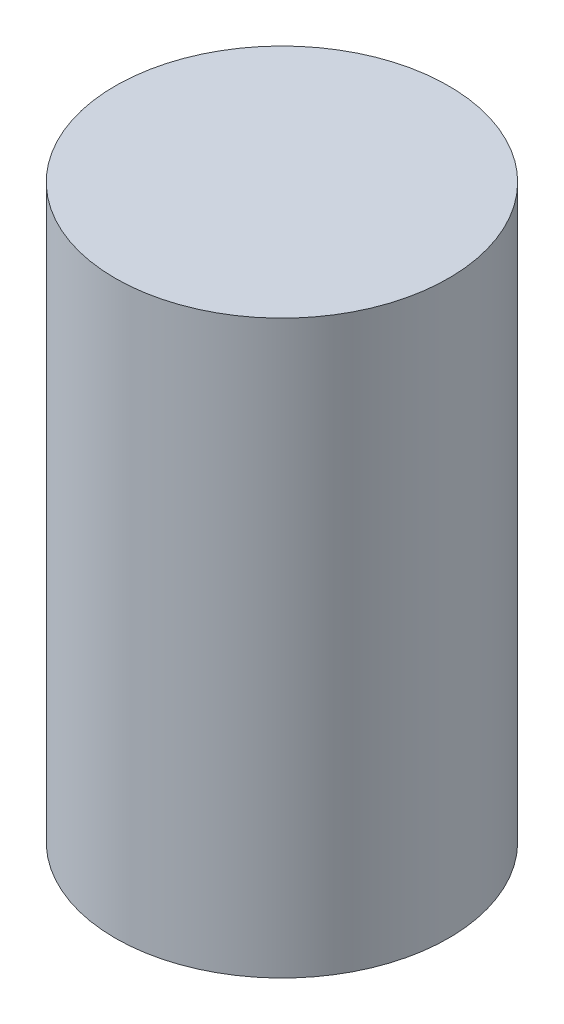
from build123d import *

# Parameters (mm, degrees)
SKETCH1_R           = 44.45
BOSS_EXTRUDE1_DEPTH = 76.2


with BuildPart() as part:
    # Sketch1 → Boss-Extrude1 (new body, symmetric)
    with BuildSketch(Plane(origin=(0, 0, 0), x_dir=(1, 0, 0), z_dir=(0, 1, 0))):
        Circle(SKETCH1_R)
    extrude(amount=BOSS_EXTRUDE1_DEPTH, both=True)


solid = part.part
